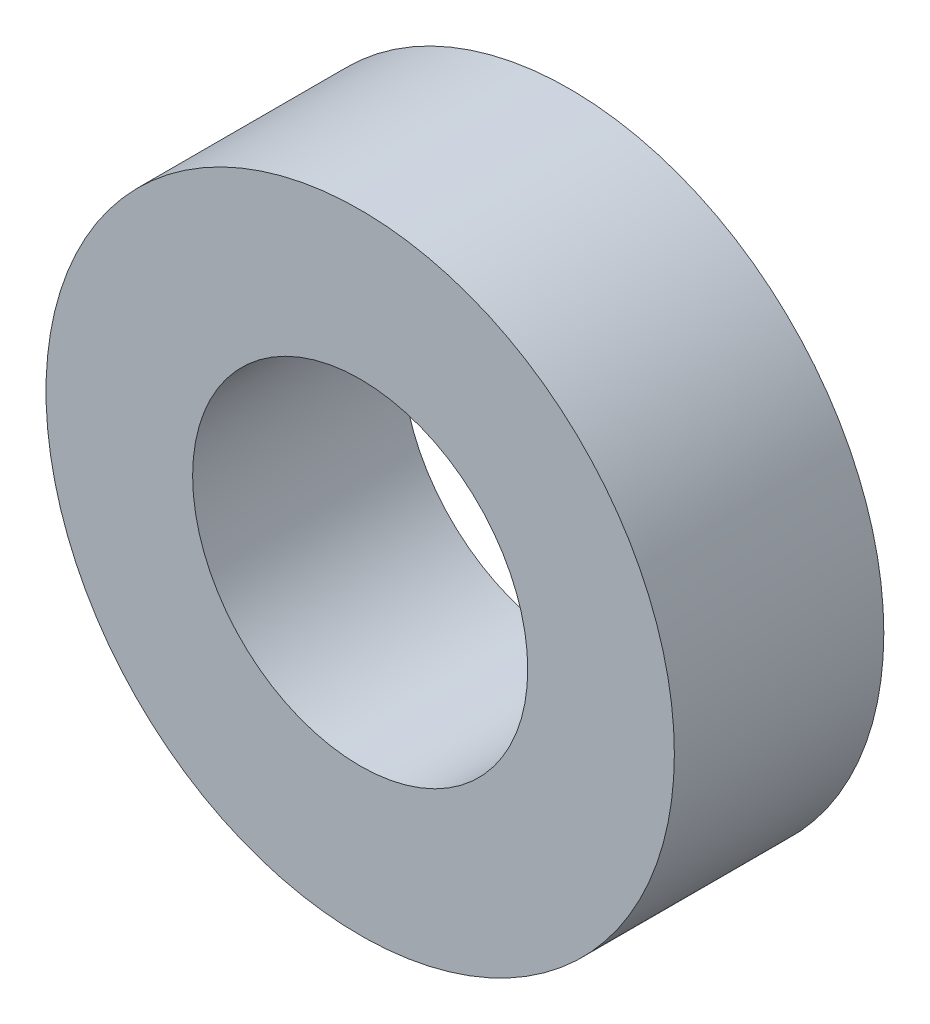
from build123d import *

# Parameters (mm, degrees)
SKETCH1_R           = 3
SKETCH1_R_2         = 1.6
EXTRUDE1_DEPTH      = 1
EXTRUDE1_DEPTH_BACK = 1


with BuildPart() as part:
    # Sketch1 → Extrude1 (new body, two sides)
    with BuildSketch(Plane.XY) as extrude1_sk:
        Circle(SKETCH1_R)
        Circle(SKETCH1_R_2, mode=Mode.SUBTRACT)
    extrude(amount=EXTRUDE1_DEPTH)
    extrude(extrude1_sk.sketch, amount=-EXTRUDE1_DEPTH_BACK)


solid = part.part
